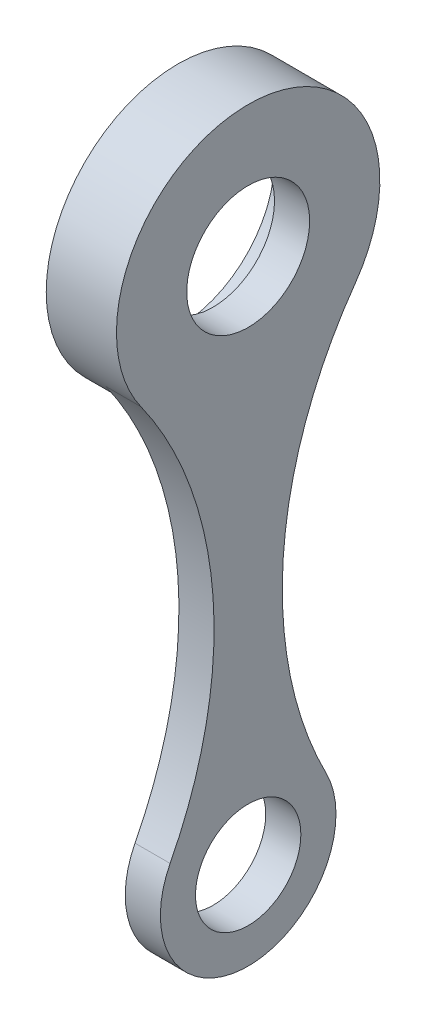
from build123d import *
from build123d.topology import SkipClean

# Parameters (mm, degrees)
SKETCH1_R           = 17.5
SKETCH1_R_2         = 15
BOSS_EXTRUDE1_DEPTH = 10
BOSS_EXTRUDE2_START = 10
SKETCH2_R           = 37.5
SKETCH2_R_2         = 27.5
BOSS_EXTRUDE2_DEPTH = 10


with BuildPart() as part:
    # Sketch1 → Boss-Extrude1 (new body)
    with BuildSketch(Plane(origin=(0, 0, 0), x_dir=(0, 0, -1), z_dir=(1, 0, 0))):
        with BuildLine():
            ThreePointArc((-30.555677848, -21.739377894), (-10, -78.973363491), (-22.221723794, -138.545961778))
            ThreePointArc((-22.221723794, -138.545961778), (0, -175), (22.221723794, -138.545961778))
            ThreePointArc((22.221723794, -138.545961778), (10, -78.973363491), (30.555677848, -21.739377894))
            ThreePointArc((30.555677848, -21.739377894), (0, 37.5), (-30.555677848, -21.739377894))
        make_face()
        Circle(SKETCH1_R, mode=Mode.SUBTRACT)
        with Locations((0, -150)):
            Circle(SKETCH1_R_2, mode=Mode.SUBTRACT)
    extrude(amount=BOSS_EXTRUDE1_DEPTH)

    # Sketch2 → Boss-Extrude2 (add)
    with SkipClean():  # the faces are left unmerged after this step: merging them gives an invalid solid
        with BuildSketch(Plane.ZY.offset(BOSS_EXTRUDE2_START)):
            Circle(SKETCH2_R)
            Circle(SKETCH2_R_2, mode=Mode.SUBTRACT)
        extrude(amount=-BOSS_EXTRUDE2_DEPTH)


solid = part.part
